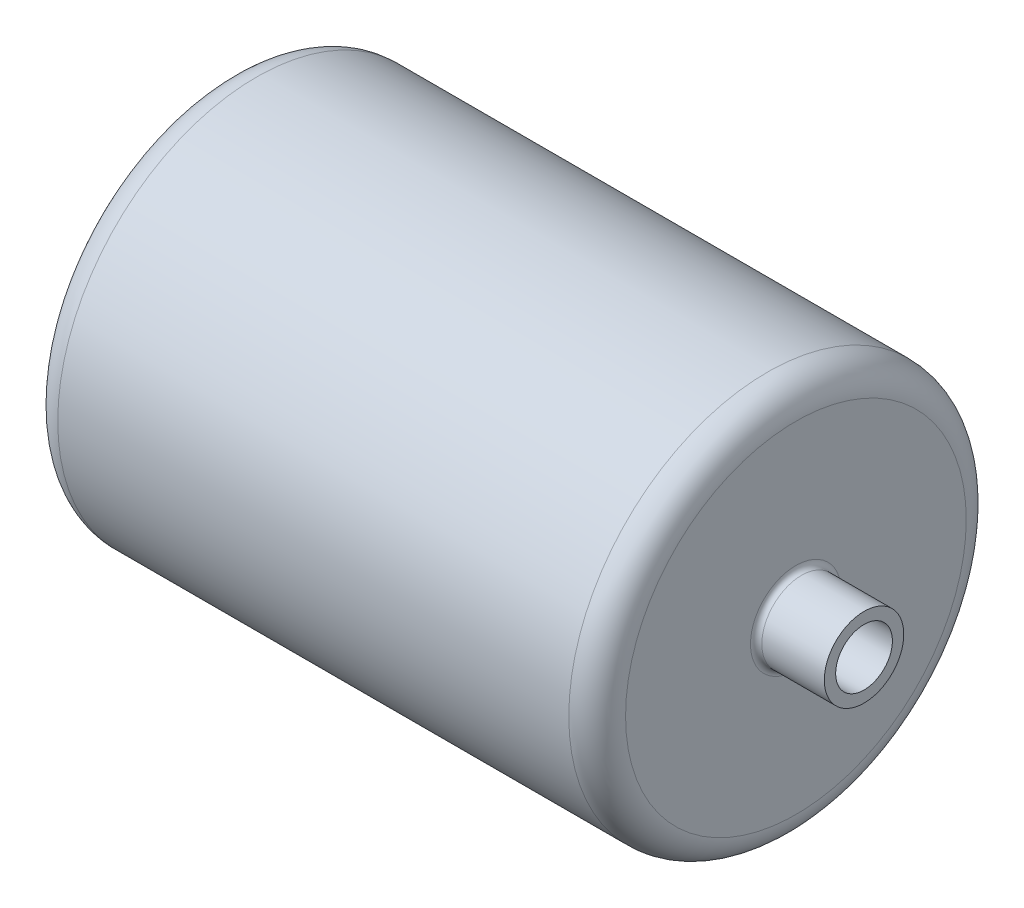
from build123d import *

# Parameters (mm, degrees)
PIPE_CONNECTOR_FILLET_R = 5


with BuildPart() as part:
    # Sketch1 → Revolve1 (revolve)
    with BuildSketch(Plane.XY):
        with BuildLine():
            Line((-225, 175), (225, 175))
            ThreePointArc((225, 175), (242.67766953, 167.67766953), (250, 150))
            Line((250, 150), (250, 35))
            Line((250, 35), (310, 35))
            Line((310, 35), (310, 25))
            Line((310, 25), (225, 25))
            Line((225, 25), (225, 137.5))
            ThreePointArc((225, 137.5), (221.338834765, 146.338834765), (212.5, 150))
            Line((212.5, 150), (-212.5, 150))
            ThreePointArc((-212.5, 150), (-221.338834765, 146.338834765), (-225, 137.5))
            Line((-225, 137.5), (-225, 0))
            Line((-225, 0), (-250, 0))
            Line((-250, 0), (-250, 150))
            ThreePointArc((-250, 150), (-242.67766953, 167.67766953), (-225, 175))
        make_face()
    revolve(axis=Axis((-162.28666216, 0, 0), (1, 0, 0)))

    # Pipe Connector Fillet
    pipe_connector_fillet_edges = [part.edges().sort_by_distance(p)[0] for p in [
        (250, -35, 0),
    ]]
    fillet(pipe_connector_fillet_edges, radius=PIPE_CONNECTOR_FILLET_R)


solid = part.part
